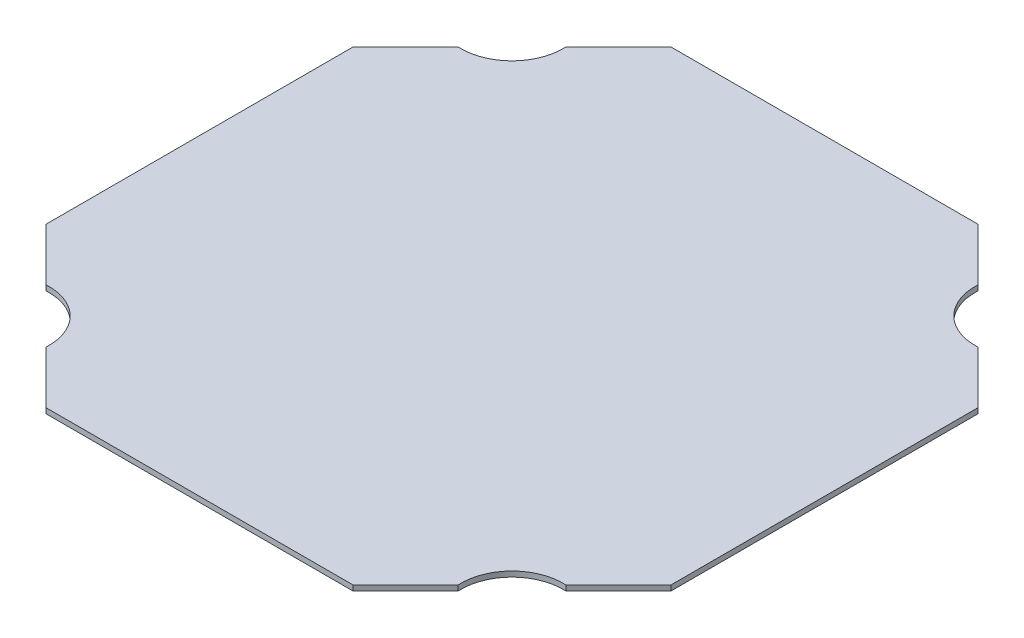
from build123d import *

# Parameters (mm, degrees)
BOSS_EXTRUDE1_DEPTH = 6.35


with BuildPart() as part:
    # Sketch1 → Boss-Extrude1 (new body)
    with BuildSketch(Plane(origin=(0, 0, 0), x_dir=(1, 0, 0), z_dir=(0, 1, 0))):
        with BuildLine():
            Line((127.578922036, 62.921077964), (190.5, 0))
            Line((190.5, 0), (558.8, 0))
            Line((558.8, 0), (621.721077964, 62.921077964))
            ThreePointArc((621.721077964, 62.921077964), (639.520218393, 109.779781607), (686.378922036, 127.578922036))
            Line((686.378922036, 127.578922036), (749.3, 190.5))
            Line((749.3, 190.5), (749.3, 558.8))
            Line((749.3, 558.8), (686.378922036, 621.721077964))
            ThreePointArc((686.378922036, 621.721077964), (639.520218393, 639.520218393), (621.721077964, 686.378922036))
            Line((621.721077964, 686.378922036), (558.8, 749.3))
            Line((558.8, 749.3), (190.5, 749.3))
            Line((190.5, 749.3), (127.578922036, 686.378922036))
            ThreePointArc((127.578922036, 686.378922036), (109.779781607, 639.520218393), (62.921077964, 621.721077964))
            Line((62.921077964, 621.721077964), (0, 558.8))
            Line((0, 558.8), (0, 190.5))
            Line((0, 190.5), (62.921077964, 127.578922036))
            ThreePointArc((62.921077964, 127.578922036), (109.779781607, 109.779781607), (127.578922036, 62.921077964))
        make_face()
    extrude(amount=BOSS_EXTRUDE1_DEPTH)


solid = part.part
